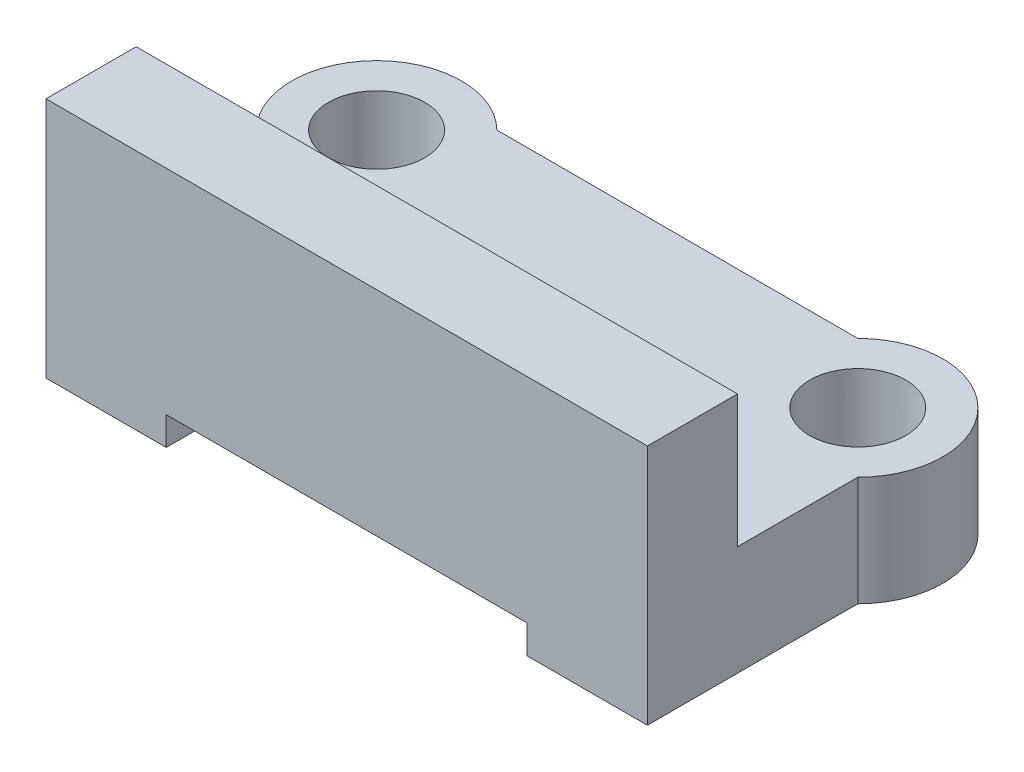
from build123d import *

# Parameters (mm, degrees)
BOSS_EXTRUDE1_DEPTH      = 3
SKETCH2_W                = 20.0076
SKETCH2_H                = 4.999999987
BOSS_EXTRUDE2_DEPTH      = 8
BOSS_EXTRUDE3_DEPTH      = 8
SKETCH4_W                = 12.0076
SKETCH4_H                = 1.4
CUT_EXTRUDE1_DEPTH       = 27.7
M3_CLEARANCE_HOLE1_D     = 3.2
M3_CLEARANCE_HOLE1_DEPTH = 15.5
M3_CLEARANCE_HOLE1_TIP   = 0.96137699
SKETCH7_W                = 8
SKETCH7_H                = 0.4
CUT_EXTRUDE2_DEPTH       = 28.5
BOSS_EXTRUDE4_DEPTH      = 4.6
BOSS_EXTRUDE5_DEPTH      = 3.647111
SKETCH10_W               = 25.759770256
SKETCH10_H               = 7.605956873
CUT_EXTRUDE3_DEPTH       = 15


with BuildPart() as part:
    # Sketch1 → Boss-Extrude1 (new body)
    with BuildSketch(Plane.XY):
        Polygon((24.618539046, -84.902707764), (24.618539046, -85.849818272), (20.618539046, -85.849818272), (20.618539046, -73.202707764), (40.626139046, -73.202707764), (40.626139046, -85.849818272), (36.626139046, -85.849818272), (36.626139046, -84.902707764), align=None)
    extrude(amount=BOSS_EXTRUDE1_DEPTH)

    # Sketch2 → Boss-Extrude2 (add)
    with BuildSketch(Plane(origin=(0, 0, 0), x_dir=(-1, 0, 0), z_dir=(0, 0, -1))):
        with Locations((-30.622339046, -75.702707758)):
            Rectangle(SKETCH2_W, SKETCH2_H)
    extrude(amount=BOSS_EXTRUDE2_DEPTH)

    # Sketch3 → Boss-Extrude3 (add)
    with BuildSketch(Plane(origin=(0, 0, 0), x_dir=(-1, 0, 0), z_dir=(0, 0, -1))):
        Polygon((-40.626139046, -82.202707751), (-40.626139046, -85.849818272), (-36.626139046, -85.849818272), (-36.626139046, -84.902707764), (-24.618539046, -84.902707764), (-24.618539046, -85.849818272), (-20.618539046, -85.849818272), (-20.618539046, -82.202707751), align=None)
    extrude(amount=BOSS_EXTRUDE3_DEPTH)

    # Sketch4 → Cut-Extrude1 (cut)
    with BuildSketch(Plane.XY.offset(3)):
        with Locations((30.622339046, -73.902707764)):
            Rectangle(SKETCH4_W, SKETCH4_H)
    extrude(amount=-CUT_EXTRUDE1_DEPTH, mode=Mode.SUBTRACT)

    # M3 Clearance Hole1
    with Locations(Plane(origin=(0, -73.202707764, 0), x_dir=(1, 0, 0), z_dir=(0, 1, 0))):
        with Locations((22.618539046, 6), (38.626139046, 6)):
            Hole(M3_CLEARANCE_HOLE1_D / 2, depth=M3_CLEARANCE_HOLE1_DEPTH)
            with Locations((0, 0, -(M3_CLEARANCE_HOLE1_DEPTH + M3_CLEARANCE_HOLE1_TIP / 2))):  # 118° drill point
                Cone(0, M3_CLEARANCE_HOLE1_D / 2, M3_CLEARANCE_HOLE1_TIP, mode=Mode.SUBTRACT)

    # Sketch7 → Cut-Extrude2 (cut)
    with BuildSketch(Plane(origin=(40.626139046, 0, 0), x_dir=(0, 0, -1), z_dir=(1, 0, 0))):
        with Locations((4, -78.002707751)):
            Rectangle(SKETCH7_W, SKETCH7_H)
    extrude(amount=-CUT_EXTRUDE2_DEPTH, mode=Mode.SUBTRACT)

    # Sketch8 → Boss-Extrude4 (add)
    with BuildSketch(Plane(origin=(0, -73.202707764, 0), x_dir=(1, 0, 0), z_dir=(0, 1, 0))):
        with BuildLine():
            ThreePointArc((24.618539046, 8), (22.618539046, 8.828427125), (20.618539046, 8))
            Line((20.618539046, 8), (24.618539046, 8))
        make_face()
        with BuildLine():
            ThreePointArc((20.618539046, 8), (19.790111921, 6), (20.618539046, 4))
            Line((20.618539046, 4), (20.618539046, 8))
        make_face()
        with BuildLine():
            Line((36.626139046, 8), (40.626139046, 8))
            ThreePointArc((40.626139046, 8), (38.626139046, 8.828427125), (36.626139046, 8))
        make_face()
        with BuildLine():
            ThreePointArc((40.626139046, 4), (41.45456617, 6), (40.626139046, 8))
            Line((40.626139046, 8), (40.626139046, 4))
        make_face()
    extrude(amount=-BOSS_EXTRUDE4_DEPTH)

    # Sketch9 → Boss-Extrude5 (add)
    with BuildSketch(Plane.XZ.offset(85.849818272)):
        with BuildLine():
            Line((20.618539046, -8), (20.618539046, -4))
            ThreePointArc((20.618539046, -4), (19.790111921, -6), (20.618539046, -8))
        make_face()
        with BuildLine():
            Line((24.618539046, -8), (20.618539046, -8))
            ThreePointArc((20.618539046, -8), (22.618539046, -8.828427125), (24.618539046, -8))
        make_face()
        with BuildLine():
            Line((40.626139046, -8), (36.626139046, -8))
            ThreePointArc((36.626139046, -8), (38.626139046, -8.828427125), (40.626139046, -8))
        make_face()
        with BuildLine():
            Line((40.626139046, -4), (40.626139046, -8))
            ThreePointArc((40.626139046, -8), (41.45456617, -6), (40.626139046, -4))
        make_face()
    extrude(amount=-BOSS_EXTRUDE5_DEPTH)

    # Sketch10 → Cut-Extrude3 (cut)
    with BuildSketch(Plane.XY.offset(3)):
        with Locations((29.890783296, -73.999729313)):
            Rectangle(SKETCH10_W, SKETCH10_H)
    extrude(amount=-CUT_EXTRUDE3_DEPTH, mode=Mode.SUBTRACT)


solid = part.part
